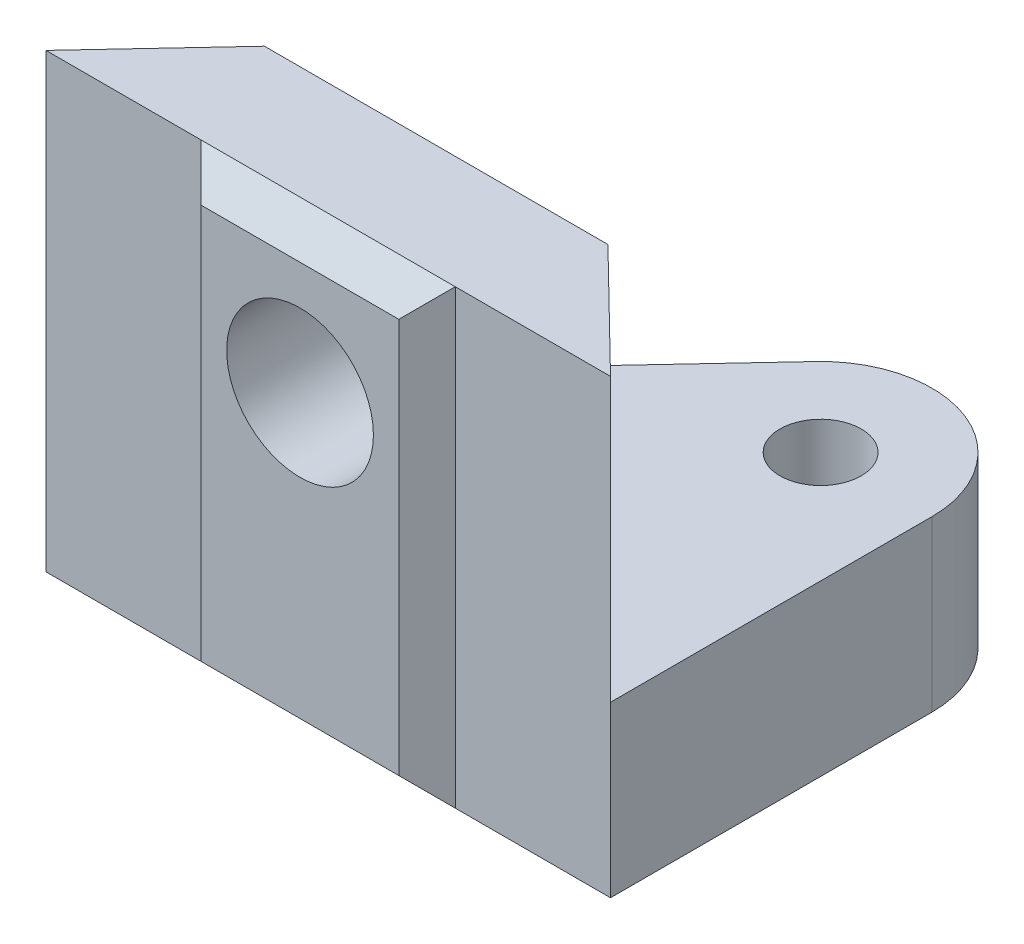
from build123d import *

# Parameters (mm, degrees)
BOSS_EXTRUDE1_DEPTH = 16
SKETCH2_W           = 9
SKETCH2_H           = 16
BOSS_EXTRUDE2_DEPTH = 1
BOSS_EXTRUDE2_TAPER = 45
SKETCH3_R           = 2.6
CUT_EXTRUDE1_DEPTH  = 6
SKETCH4_R           = 1.44
BOSS_EXTRUDE3_DEPTH = 6


with BuildPart() as part:
    # Sketch1 → Boss-Extrude1 (new body)
    with BuildSketch(Plane(origin=(0, 0, 0), x_dir=(1, 0, 0), z_dir=(0, 1, 0))):
        Polygon((-6.542273602, -4.737945966), (13.457726398, -4.737945966), (9.36611498, -0.737945966), (-2.80088502, -0.737945966), align=None)
    extrude(amount=-BOSS_EXTRUDE1_DEPTH)

    # Sketch2 → Boss-Extrude2 (add)
    with BuildSketch(Plane.XY.offset(4.737945966)):
        with Locations((3.457726398, -8)):
            Rectangle(SKETCH2_W, SKETCH2_H)
    extrude(amount=BOSS_EXTRUDE2_DEPTH, taper=BOSS_EXTRUDE2_TAPER)

    # Sketch3 → Cut-Extrude1 (cut, through all)
    with BuildSketch(Plane.XY.offset(5.737945966)):
        with Locations((3.457726398, -5)):
            Circle(SKETCH3_R)
    extrude(amount=-CUT_EXTRUDE1_DEPTH, mode=Mode.SUBTRACT)

    # Sketch4 → Boss-Extrude3 (add)
    with BuildSketch(Plane.XZ.offset(16)):
        with BuildLine():
            Line((13.457726398, 4.737945966), (13.457726398, -6.650054034))
            ThreePointArc((13.457726398, -6.650054034), (10.961456039, -10.319414663), (6.631765726, -9.345066204))
            Line((6.631765726, -9.345066204), (-6.542273602, 4.737945966))
            Line((-6.542273602, 4.737945966), (13.457726398, 4.737945966))
        make_face()
        with Locations((9.512726398, -6.650054034)):
            Circle(SKETCH4_R, mode=Mode.SUBTRACT)
    extrude(amount=-BOSS_EXTRUDE3_DEPTH)


solid = part.part
